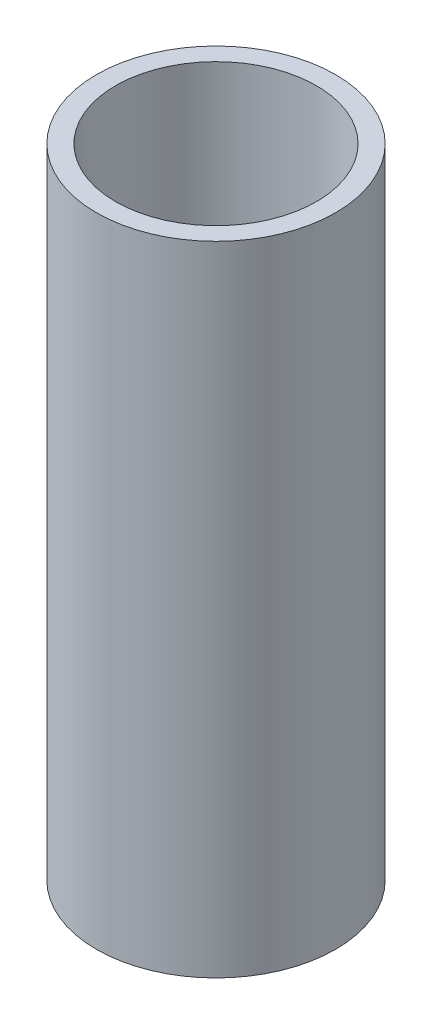
from build123d import *

# Parameters (mm, degrees)
SKETCH1_R                        = 9.525
BOSS_EXTRUDE1_DEPTH              = 50.8
F_16_0_16_DIAMETER_HOLE1_D       = 16
F_16_0_16_DIAMETER_HOLE1_DEPTH   = 25.4
F_16_0_16_DIAMETER_HOLE1_TIP     = 4.806884952
F_3_8_0_375_DIAMETER_HOLE1_D     = 9.525
F_3_8_0_375_DIAMETER_HOLE1_DEPTH = 17.78
F_3_8_0_375_DIAMETER_HOLE1_TIP   = 2.861598698


with BuildPart() as part:
    # Sketch1 → Boss-Extrude1 (new body)
    with BuildSketch(Plane(origin=(0, 0, 0), x_dir=(1, 0, 0), z_dir=(0, 1, 0))):
        Circle(SKETCH1_R)
    extrude(amount=BOSS_EXTRUDE1_DEPTH)

    # Ø16.0 (16) Diameter Hole1
    with Locations(Plane(origin=(0, 50.8, 0), x_dir=(1, 0, 0), z_dir=(0, 1, 0))):
        with Locations((0, 0)):
            Hole(F_16_0_16_DIAMETER_HOLE1_D / 2, depth=F_16_0_16_DIAMETER_HOLE1_DEPTH)
            with Locations((0, 0, -(F_16_0_16_DIAMETER_HOLE1_DEPTH + F_16_0_16_DIAMETER_HOLE1_TIP / 2))):  # 118° drill point
                Cone(0, F_16_0_16_DIAMETER_HOLE1_D / 2, F_16_0_16_DIAMETER_HOLE1_TIP, mode=Mode.SUBTRACT)

    # 3/8 (0.375) Diameter Hole1
    with Locations(Plane(origin=(0, 0, 0), x_dir=(-1, 0, 0), z_dir=(0, -1, 0))):
        with Locations((0, 0)):
            Hole(F_3_8_0_375_DIAMETER_HOLE1_D / 2, depth=F_3_8_0_375_DIAMETER_HOLE1_DEPTH)
            with Locations((0, 0, -(F_3_8_0_375_DIAMETER_HOLE1_DEPTH + F_3_8_0_375_DIAMETER_HOLE1_TIP / 2))):  # 118° drill point
                Cone(0, F_3_8_0_375_DIAMETER_HOLE1_D / 2, F_3_8_0_375_DIAMETER_HOLE1_TIP, mode=Mode.SUBTRACT)


solid = part.part
